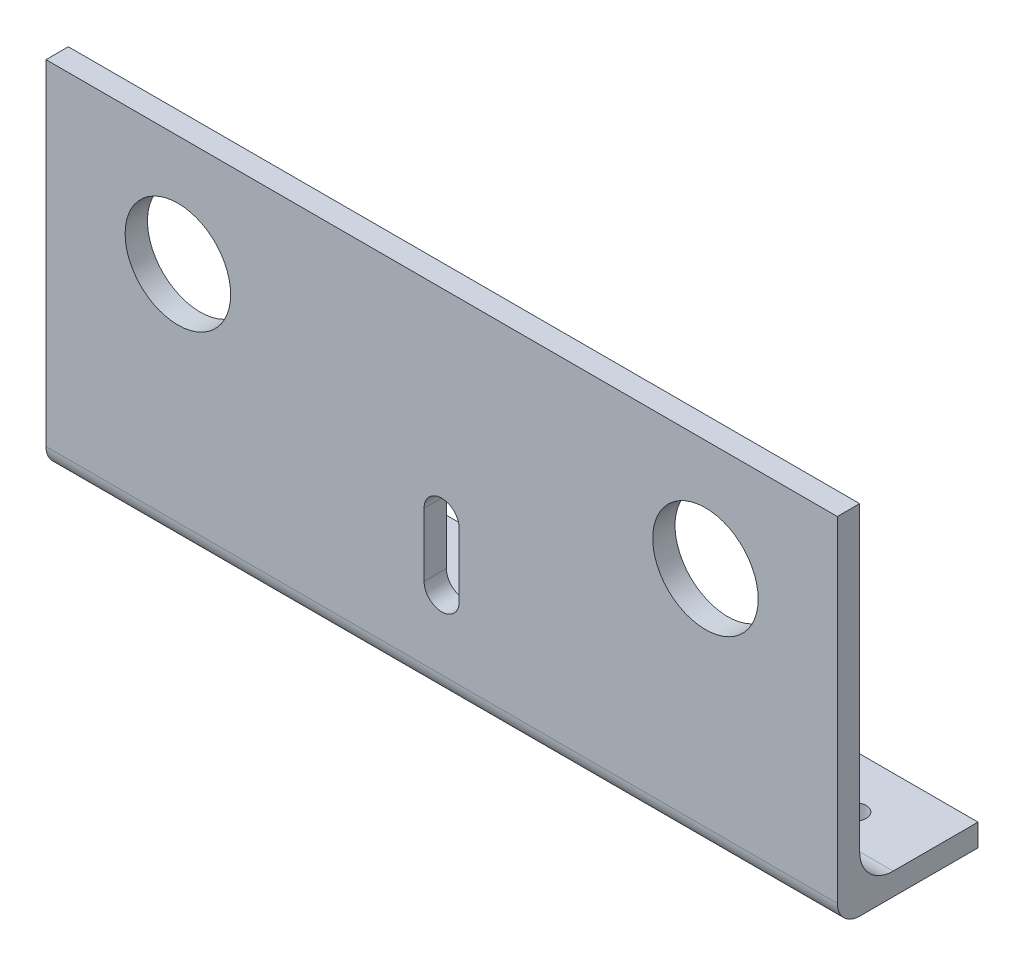
from build123d import *

# Parameters (mm, degrees)
BOSS_EXTRUDE1_DEPTH  = 225
FILLET1_R            = 6.35
SKETCH2_R            = 15
CUT_EXTRUDE1_DEPTH   = 75
CUT_EXTRUDE2_DEPTH   = 10
M6_CLEARANCE_HOLE1_D = 6.4


with BuildPart() as part:
    # Sketch1 → Boss-Extrude1 (new body)
    with BuildSketch(Plane(origin=(0, 0, 0), x_dir=(0, 0, -1), z_dir=(1, 0, 0))):
        with BuildLine():
            Line((0, 0), (0, 101.6))
            Line((0, 101.6), (6.35, 101.6))
            Line((6.35, 101.6), (6.35, 15.875))
            ThreePointArc((6.35, 15.875), (9.139807909, 9.139807909), (15.875, 6.35))
            Line((15.875, 6.35), (40, 6.35))
            Line((40, 6.35), (40, 0))
            Line((40, 0), (0, 0))
        make_face()
    extrude(amount=BOSS_EXTRUDE1_DEPTH)

    # Fillet1
    fillet1_edges = [part.edges().sort_by_distance(p)[0] for p in [
        (112.5, 0, 0),
    ]]
    fillet(fillet1_edges, radius=FILLET1_R)

    # Sketch2 → Cut-Extrude1 (cut)
    with BuildSketch(Plane(origin=(0, 0, 0), x_dir=(-1, 0, 0), z_dir=(0, 0, -1))):
        with Locations((-37.5, 70)):
            Circle(SKETCH2_R)
        with Locations((-187.5, 70)):
            Circle(SKETCH2_R)
    extrude(amount=CUT_EXTRUDE1_DEPTH, mode=Mode.SUBTRACT)

    # Sketch5 → Cut-Extrude2 (cut)
    with BuildSketch(Plane(origin=(0, 0, -6.35), x_dir=(-1, 0, 0), z_dir=(0, 0, -1))):
        with BuildLine():
            Line((-107.5, 44.875), (-107.5, 26.875))
            ThreePointArc((-107.5, 26.875), (-112.5, 21.875), (-117.5, 26.875))
            Line((-117.5, 26.875), (-117.5, 44.875))
            ThreePointArc((-117.5, 44.875), (-112.5, 49.875), (-107.5, 44.875))
        make_face()
    extrude(amount=-CUT_EXTRUDE2_DEPTH, mode=Mode.SUBTRACT)

    # M6 Clearance Hole1 (through all)
    with Locations(Plane(origin=(20, 0, -25), x_dir=(0, 0, -1), z_dir=(0, -1, 0))):
        with Locations((0, 0), (0, 50), (0, 135), (0, 185)):
            Hole(M6_CLEARANCE_HOLE1_D / 2)


solid = part.part
